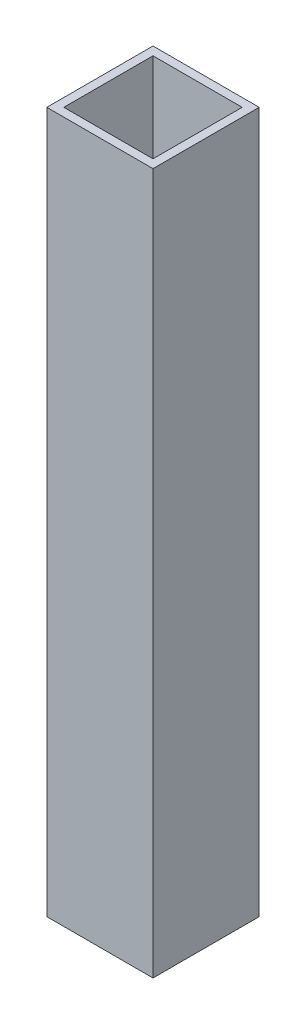
from build123d import *

# Parameters (mm, degrees)
SKETCH1_W           = 25
SKETCH1_H           = 25
SKETCH1_W_2         = 21
SKETCH1_H_2         = 21
BOSS_EXTRUDE1_DEPTH = 165


with BuildPart() as part:
    # Sketch1 → Boss-Extrude1 (new body)
    with BuildSketch(Plane(origin=(0, 0, 0), x_dir=(1, 0, 0), z_dir=(0, 1, 0))):
        Rectangle(SKETCH1_W, SKETCH1_H)
        Rectangle(SKETCH1_W_2, SKETCH1_H_2, mode=Mode.SUBTRACT)
    extrude(amount=BOSS_EXTRUDE1_DEPTH)


solid = part.part
